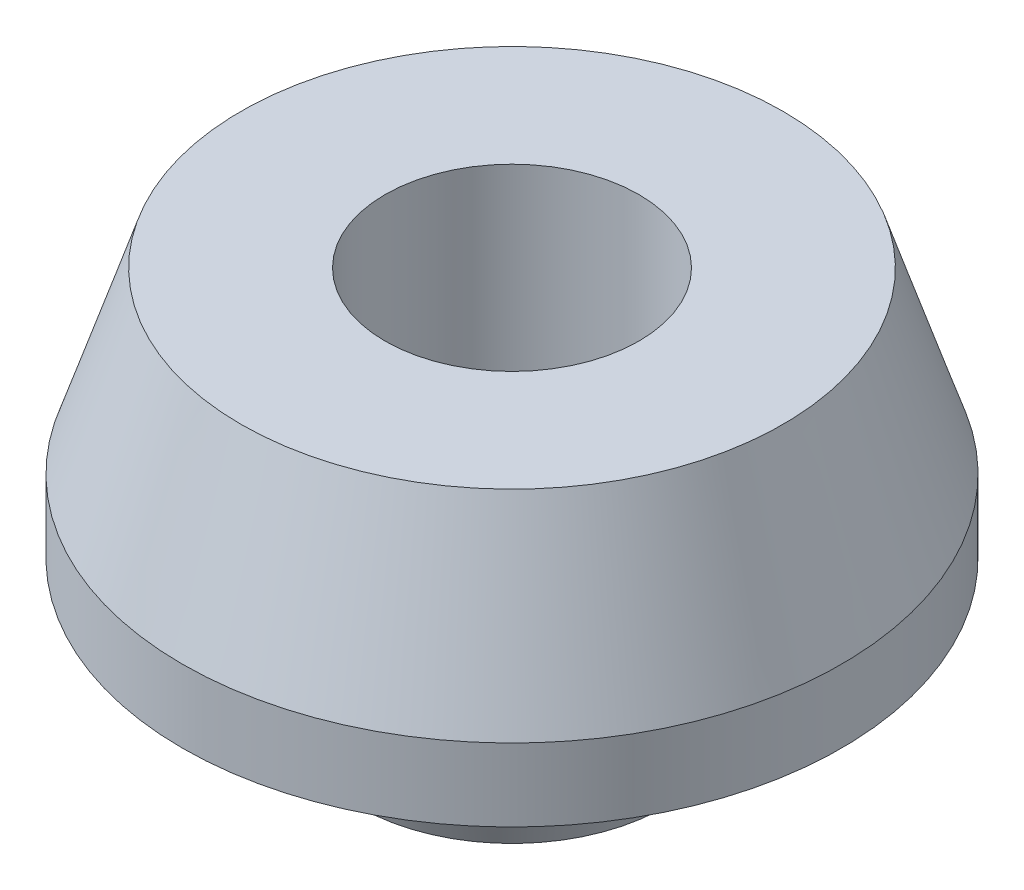
from build123d import *


with BuildPart() as part:
    # Sketch2 → Revolve1 (revolve)
    with BuildSketch(Plane.XY):
        Polygon((4.8, 0), (4.8, 14.75), (10.25, 14.75), (12.46084373, 8), (12.46084373, 5.25), (7.71084373, 5.25), (5.8, 0), align=None)
    revolve(axis=Axis((0, 0, 0), (0, 1, 0)))


solid = part.part
